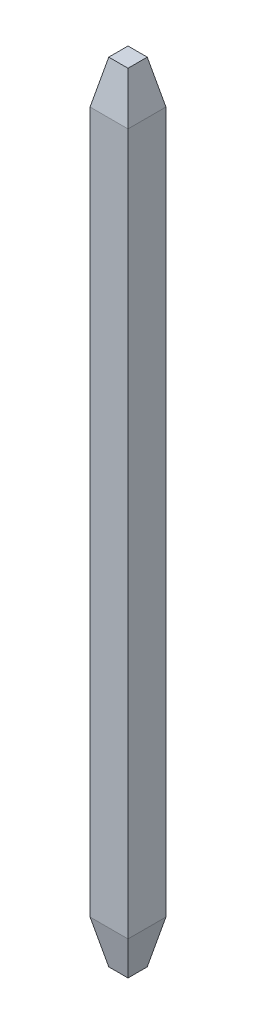
from build123d import *

# Parameters (mm, degrees)
SKETCH1_W             = 0.65
SKETCH1_H             = 0.65
BOSS_EXTRUDE1_DEPTH   = 13.5
CHAMFER1_SIZE         = 0.74
CHAMFER1_SIZE2        = 0.16
CHAMFER1_PART_2_SIZE  = 0.74
CHAMFER1_PART_2_SIZE2 = 0.16
CHAMFER1_PART_3_SIZE  = 0.74
CHAMFER1_PART_3_SIZE2 = 0.16
CHAMFER1_PART_4_SIZE  = 0.74
CHAMFER1_PART_4_SIZE2 = 0.16
CHAMFER2_SIZE         = 0.16
CHAMFER2_SIZE2        = 0.74


with BuildPart() as part:
    # Sketch1 → Boss-Extrude1 (new body)
    with BuildSketch(Plane(origin=(0, 0, 0), x_dir=(1, 0, 0), z_dir=(0, 1, 0))):
        with Locations((0.325, 0.325)):
            Rectangle(SKETCH1_W, SKETCH1_H)
    extrude(amount=BOSS_EXTRUDE1_DEPTH)

    # Chamfer1
    chamfer1_edges = [part.edges().sort_by_distance(p)[0] for p in [
        (0.65, 13.5, -0.325),
    ]]
    chamfer1_side = [part.faces().sort_by_distance(p)[0] for p in [
        (0.65, 6.75, -0.325),
    ]]
    chamfer(chamfer1_edges, length=CHAMFER1_SIZE, length2=CHAMFER1_SIZE2, reference=chamfer1_side[0])

    # Chamfer1 part 2
    chamfer1_part_2_edges = [part.edges().sort_by_distance(p)[0] for p in [
        (0.325, 13.5, -0.65),
    ]]
    chamfer1_part_2_side = [part.faces().sort_by_distance(p)[0] for p in [
        (0.325, 6.75, -0.65),
    ]]
    chamfer(chamfer1_part_2_edges, length=CHAMFER1_PART_2_SIZE, length2=CHAMFER1_PART_2_SIZE2, reference=chamfer1_part_2_side[0])

    # Chamfer1 part 3
    chamfer1_part_3_edges = [part.edges().sort_by_distance(p)[0] for p in [
        (0, 13.5, -0.325),
    ]]
    chamfer1_part_3_side = [part.faces().sort_by_distance(p)[0] for p in [
        (0, 6.75, -0.325),
    ]]
    chamfer(chamfer1_part_3_edges, length=CHAMFER1_PART_3_SIZE, length2=CHAMFER1_PART_3_SIZE2, reference=chamfer1_part_3_side[0])

    # Chamfer1 part 4
    chamfer1_part_4_edges = [part.edges().sort_by_distance(p)[0] for p in [
        (0.325, 13.5, 0),
    ]]
    chamfer1_part_4_side = [part.faces().sort_by_distance(p)[0] for p in [
        (0.325, 6.75, 0),
    ]]
    chamfer(chamfer1_part_4_edges, length=CHAMFER1_PART_4_SIZE, length2=CHAMFER1_PART_4_SIZE2, reference=chamfer1_part_4_side[0])

    # Chamfer2
    chamfer2_edges = [part.edges().sort_by_distance(p)[0] for p in [
        (0.325, 0, -0.65),
        (0.65, 0, -0.325),
        (0.325, 0, 0),
        (0, 0, -0.325),
    ]]
    chamfer2_side = [part.faces().sort_by_distance(p)[0] for p in [
        (0.325, 0, -0.325),
    ]]
    chamfer(chamfer2_edges, length=CHAMFER2_SIZE, length2=CHAMFER2_SIZE2, reference=chamfer2_side[0])


solid = part.part
